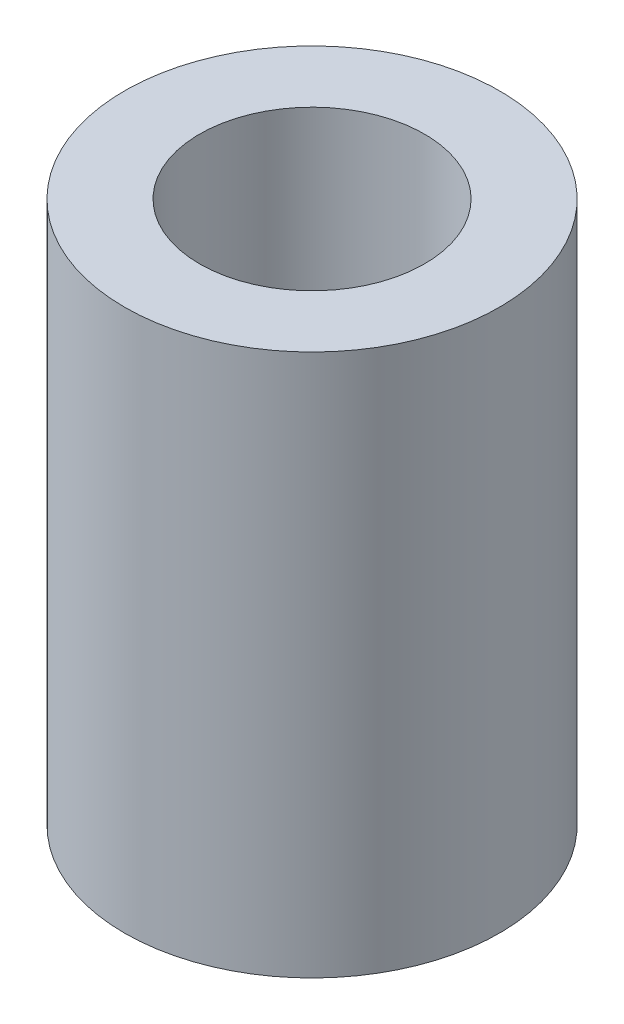
from build123d import *

# Parameters (mm, degrees)
SKETCH_1_R      = 2.5
SKETCH_1_R_2    = 1.5
EXTRUDE_1_DEPTH = 7.23


with BuildPart() as part:
    # 草图1 → 凸台-拉伸1 (new body)
    with BuildSketch(Plane(origin=(0, 0, 0), x_dir=(1, 0, 0), z_dir=(0, 1, 0))):
        Circle(SKETCH_1_R)
        Circle(SKETCH_1_R_2, mode=Mode.SUBTRACT)
    extrude(amount=EXTRUDE_1_DEPTH)


solid = part.part
